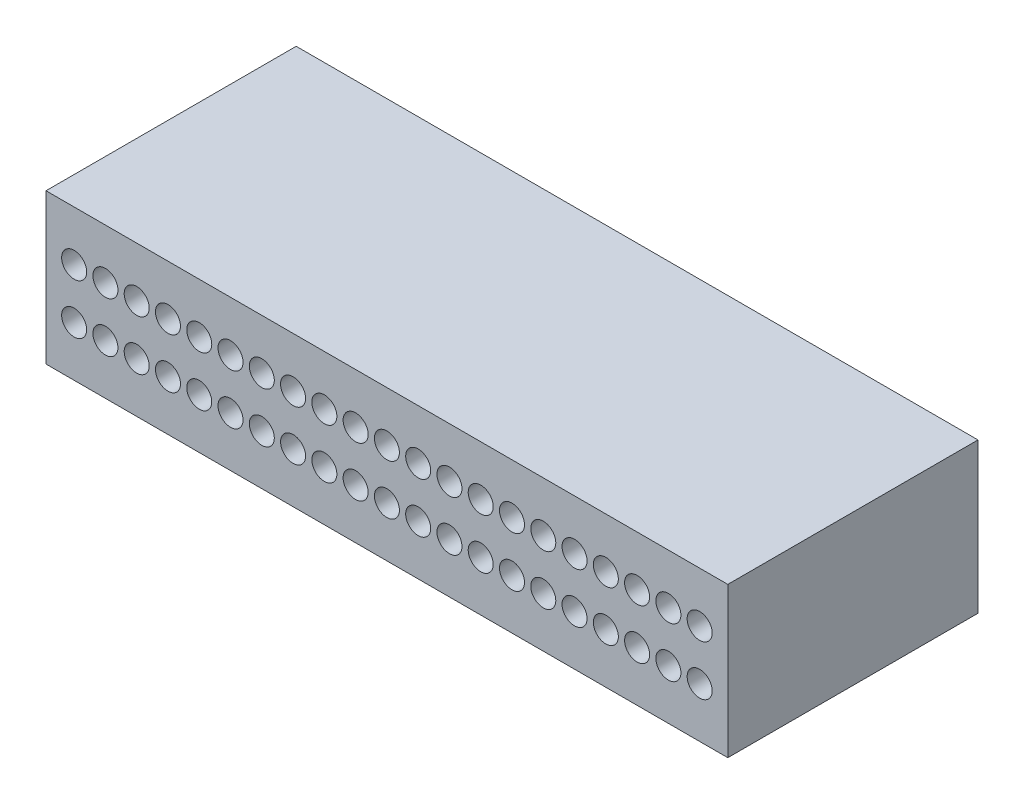
from build123d import *

# Parameters (mm, degrees)
SKETCH2_W           = 27.25
SKETCH2_H           = 6
BOSS_EXTRUDE1_DEPTH = 10
SKETCH3_R           = 0.5
CUT_EXTRUDE1_DEPTH  = 5


with BuildPart() as part:
    # Sketch2 → Boss-Extrude1 (new body)
    with BuildSketch(Plane.XY):
        with Locations((13.625, 3)):
            Rectangle(SKETCH2_W, SKETCH2_H)
    extrude(amount=BOSS_EXTRUDE1_DEPTH)

    # Sketch3 → Cut-Extrude1 (cut)
    with BuildSketch(Plane.XY.offset(10)):
        with Locations((1.125, 2)):
            Circle(SKETCH3_R)
        with Locations((2.375, 2)):
            Circle(SKETCH3_R)
        with Locations((3.625, 2)):
            Circle(SKETCH3_R)
        with Locations((4.875, 2)):
            Circle(SKETCH3_R)
        with Locations((6.125, 2)):
            Circle(SKETCH3_R)
        with Locations((7.375, 2)):
            Circle(SKETCH3_R)
        with Locations((8.625, 2)):
            Circle(SKETCH3_R)
        with Locations((9.875, 2)):
            Circle(SKETCH3_R)
        with Locations((11.125, 2)):
            Circle(SKETCH3_R)
        with Locations((12.375, 2)):
            Circle(SKETCH3_R)
        with Locations((13.625, 2)):
            Circle(SKETCH3_R)
        with Locations((14.875, 2)):
            Circle(SKETCH3_R)
        with Locations((16.125, 2)):
            Circle(SKETCH3_R)
        with Locations((17.375, 2)):
            Circle(SKETCH3_R)
        with Locations((18.625, 2)):
            Circle(SKETCH3_R)
        with Locations((19.875, 2)):
            Circle(SKETCH3_R)
        with Locations((21.125, 2)):
            Circle(SKETCH3_R)
        with Locations((22.375, 2)):
            Circle(SKETCH3_R)
        with Locations((23.625, 2)):
            Circle(SKETCH3_R)
        with Locations((24.875, 2)):
            Circle(SKETCH3_R)
        with Locations((26.125, 2)):
            Circle(SKETCH3_R)
    cut_extrude1 = extrude(amount=-CUT_EXTRUDE1_DEPTH, mode=Mode.SUBTRACT)

    # Mirror1: Cut-Extrude1 across plane
    add(cut_extrude1.mirror(Plane(origin=(0, 3, 0), x_dir=(0, 0, 1), z_dir=(0, -1, 0))), mode=Mode.SUBTRACT)


solid = part.part
